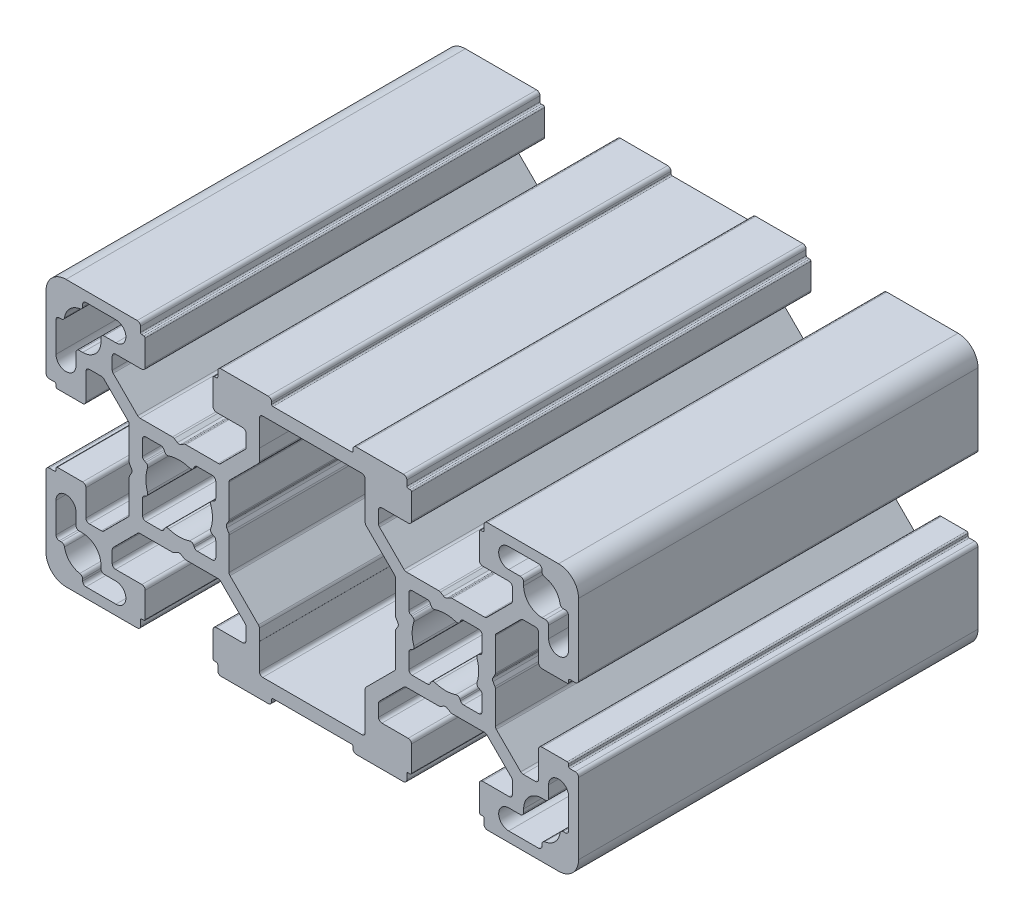
from build123d import *

# Parameters (mm, degrees)
EXTRUDE_1_DEPTH = 60


with BuildPart() as part:
    # Эскиз1 → Бобышка-Вытянуть1 (new body)
    with BuildSketch(Plane.XY):
        with BuildLine():
            Line((0.75, 7.433012702), (0.25, 7.144337567))
            ThreePointArc((0.25, 7.144337567), (0, 7.077350269), (-0.25, 7.144337567))
            Line((-0.25, 7.144337567), (-0.75, 7.433012702))
            ThreePointArc((-0.75, 7.433012702), (-0.870590477, 7.482962913), (-1, 7.5))
            Line((-1, 7.5), (-5.878679656, 7.5))
            ThreePointArc((-5.878679656, 7.5), (-6.070021373, 7.538060234), (-6.232233047, 7.646446609))
            Line((-6.232233047, 7.646446609), (-9.903553391, 11.317766953))
            ThreePointArc((-9.903553391, 11.317766953), (-10.011939766, 11.479978627), (-10.05, 11.671320344))
            Line((-10.05, 11.671320344), (-10.05, 13.5))
            ThreePointArc((-10.05, 13.5), (-9.903553391, 13.853553391), (-9.55, 14))
            Line((-9.55, 14), (-5.6, 14))
            ThreePointArc((-5.6, 14), (-5.246446609, 14.146446609), (-5.1, 14.5))
            Line((-5.1, 14.5), (-5.1, 18.3))
            ThreePointArc((-5.1, 18.3), (-5.158578644, 18.441421356), (-5.3, 18.5))
            Line((-5.3, 18.5), (-5.6, 18.5))
            ThreePointArc((-5.6, 18.5), (-5.741421356, 18.558578644), (-5.8, 18.7))
            Line((-5.8, 18.7), (-5.8, 19.5))
            ThreePointArc((-5.8, 19.5), (-5.946446609, 19.853553391), (-6.3, 20))
            Line((-6.3, 20), (-17, 20))
            ThreePointArc((-17, 20), (-19.121320344, 19.121320344), (-20, 17))
            Line((-20, 17), (-20, 6.3))
            ThreePointArc((-20, 6.3), (-19.853553391, 5.946446609), (-19.5, 5.8))
            Line((-19.5, 5.8), (-18.7, 5.8))
            ThreePointArc((-18.7, 5.8), (-18.558578644, 5.741421356), (-18.5, 5.6))
            Line((-18.5, 5.6), (-18.5, 5.3))
            ThreePointArc((-18.5, 5.3), (-18.441421356, 5.158578644), (-18.3, 5.1))
            Line((-18.3, 5.1), (-14.5, 5.1))
            ThreePointArc((-14.5, 5.1), (-14.146446609, 5.246446609), (-14, 5.6))
            Line((-14, 5.6), (-14, 9.55))
            ThreePointArc((-14, 9.55), (-13.853553391, 9.903553391), (-13.5, 10.05))
            Line((-13.5, 10.05), (-11.671320344, 10.05))
            ThreePointArc((-11.671320344, 10.05), (-11.479978627, 10.011939766), (-11.317766953, 9.903553391))
            Line((-11.317766953, 9.903553391), (-7.646446609, 6.232233047))
            ThreePointArc((-7.646446609, 6.232233047), (-7.538060234, 6.070021373), (-7.5, 5.878679656))
            Line((-7.5, 5.878679656), (-7.5, 1))
            ThreePointArc((-7.5, 1), (-7.482962913, 0.870590477), (-7.433012702, 0.75))
            Line((-7.433012702, 0.75), (-7.144337567, 0.25))
            ThreePointArc((-7.144337567, 0.25), (-7.077350269, 0), (-7.144337567, -0.25))
            Line((-7.144337567, -0.25), (-7.433012702, -0.75))
            ThreePointArc((-7.433012702, -0.75), (-7.482962913, -0.870590477), (-7.5, -1))
            Line((-7.5, -1), (-7.5, -5.878679656))
            ThreePointArc((-7.5, -5.878679656), (-7.538060234, -6.070021373), (-7.646446609, -6.232233047))
            Line((-7.646446609, -6.232233047), (-11.317766953, -9.903553391))
            ThreePointArc((-11.317766953, -9.903553391), (-11.479978627, -10.011939766), (-11.671320344, -10.05))
            Line((-11.671320344, -10.05), (-13.5, -10.05))
            ThreePointArc((-13.5, -10.05), (-13.853553391, -9.903553391), (-14, -9.55))
            Line((-14, -9.55), (-14, -5.6))
            ThreePointArc((-14, -5.6), (-14.146446609, -5.246446609), (-14.5, -5.1))
            Line((-14.5, -5.1), (-18.3, -5.1))
            ThreePointArc((-18.3, -5.1), (-18.441421356, -5.158578644), (-18.5, -5.3))
            Line((-18.5, -5.3), (-18.5, -5.6))
            ThreePointArc((-18.5, -5.6), (-18.558578644, -5.741421356), (-18.7, -5.8))
            Line((-18.7, -5.8), (-19.5, -5.8))
            ThreePointArc((-19.5, -5.8), (-19.853553391, -5.946446609), (-20, -6.3))
            Line((-20, -6.3), (-20, -17))
            ThreePointArc((-20, -17), (-19.121320344, -19.121320344), (-17, -20))
            Line((-17, -20), (-6.3, -20))
            ThreePointArc((-6.3, -20), (-5.946446609, -19.853553391), (-5.8, -19.5))
            Line((-5.8, -19.5), (-5.8, -18.7))
            ThreePointArc((-5.8, -18.7), (-5.741421356, -18.558578644), (-5.6, -18.5))
            Line((-5.6, -18.5), (-5.3, -18.5))
            ThreePointArc((-5.3, -18.5), (-5.158578644, -18.441421356), (-5.1, -18.3))
            Line((-5.1, -18.3), (-5.1, -14.5))
            ThreePointArc((-5.1, -14.5), (-5.246446609, -14.146446609), (-5.6, -14))
            Line((-5.6, -14), (-9.55, -14))
            ThreePointArc((-9.55, -14), (-9.903553391, -13.853553391), (-10.05, -13.5))
            Line((-10.05, -13.5), (-10.05, -11.671320344))
            ThreePointArc((-10.05, -11.671320344), (-10.011939766, -11.479978627), (-9.903553391, -11.317766953))
            Line((-9.903553391, -11.317766953), (-6.232233047, -7.646446609))
            ThreePointArc((-6.232233047, -7.646446609), (-6.070021373, -7.538060234), (-5.878679656, -7.5))
            Line((-5.878679656, -7.5), (-1, -7.5))
            ThreePointArc((-1, -7.5), (-0.870590477, -7.482962913), (-0.75, -7.433012702))
            Line((-0.75, -7.433012702), (-0.25, -7.144337567))
            ThreePointArc((-0.25, -7.144337567), (0, -7.077350269), (0.25, -7.144337567))
            Line((0.25, -7.144337567), (0.75, -7.433012702))
            ThreePointArc((0.75, -7.433012702), (0.870590477, -7.482962913), (1, -7.5))
            Line((1, -7.5), (5.878679656, -7.5))
            ThreePointArc((5.878679656, -7.5), (6.070021373, -7.538060234), (6.232233047, -7.646446609))
            Line((6.232233047, -7.646446609), (9.903553391, -11.317766953))
            ThreePointArc((9.903553391, -11.317766953), (10.011939766, -11.479978627), (10.05, -11.671320344))
            Line((10.05, -11.671320344), (10.05, -13.5))
            ThreePointArc((10.05, -13.5), (9.903553391, -13.853553391), (9.55, -14))
            Line((9.55, -14), (5.6, -14))
            ThreePointArc((5.6, -14), (5.246446609, -14.146446609), (5.1, -14.5))
            Line((5.1, -14.5), (5.1, -18.3))
            ThreePointArc((5.1, -18.3), (5.158578644, -18.441421356), (5.3, -18.5))
            Line((5.3, -18.5), (5.6, -18.5))
            ThreePointArc((5.6, -18.5), (5.741421356, -18.558578644), (5.8, -18.7))
            Line((5.8, -18.7), (5.8, -19.5))
            ThreePointArc((5.8, -19.5), (5.946446609, -19.853553391), (6.3, -20))
            Line((6.3, -20), (13.39, -20))
            ThreePointArc((13.39, -20), (13.743553391, -19.853553391), (13.89, -19.5))
            Line((13.89, -19.5), (13.89, -19.2))
            ThreePointArc((13.89, -19.2), (13.948578644, -19.058578644), (14.09, -19))
            Line((14.09, -19), (25.91, -19))
            ThreePointArc((25.91, -19), (26.051421356, -19.058578644), (26.11, -19.2))
            Line((26.11, -19.2), (26.11, -19.5))
            ThreePointArc((26.11, -19.5), (26.256446609, -19.853553391), (26.61, -20))
            Line((26.61, -20), (33.7, -20))
            ThreePointArc((33.7, -20), (34.053553391, -19.853553391), (34.2, -19.5))
            Line((34.2, -19.5), (34.2, -18.7))
            ThreePointArc((34.2, -18.7), (34.258578644, -18.558578644), (34.4, -18.5))
            Line((34.4, -18.5), (34.7, -18.5))
            ThreePointArc((34.7, -18.5), (34.841421356, -18.441421356), (34.9, -18.3))
            Line((34.9, -18.3), (34.9, -14.5))
            ThreePointArc((34.9, -14.5), (34.753553391, -14.146446609), (34.4, -14))
            Line((34.4, -14), (30.45, -14))
            ThreePointArc((30.45, -14), (30.096446609, -13.853553391), (29.95, -13.5))
            Line((29.95, -13.5), (29.95, -11.671320344))
            ThreePointArc((29.95, -11.671320344), (29.988060234, -11.479978627), (30.096446609, -11.317766953))
            Line((30.096446609, -11.317766953), (33.767766953, -7.646446609))
            ThreePointArc((33.767766953, -7.646446609), (33.929978627, -7.538060234), (34.121320344, -7.5))
            Line((34.121320344, -7.5), (39, -7.5))
            ThreePointArc((39, -7.5), (39.129409523, -7.482962913), (39.25, -7.433012702))
            Line((39.25, -7.433012702), (39.75, -7.144337567))
            ThreePointArc((39.75, -7.144337567), (40, -7.077350269), (40.25, -7.144337567))
            Line((40.25, -7.144337567), (40.75, -7.433012702))
            ThreePointArc((40.75, -7.433012702), (40.870590477, -7.482962913), (41, -7.5))
            Line((41, -7.5), (45.878679656, -7.5))
            ThreePointArc((45.878679656, -7.5), (46.070021373, -7.538060234), (46.232233047, -7.646446609))
            Line((46.232233047, -7.646446609), (49.903553391, -11.317766953))
            ThreePointArc((49.903553391, -11.317766953), (50.011939766, -11.479978627), (50.05, -11.671320344))
            Line((50.05, -11.671320344), (50.05, -13.5))
            ThreePointArc((50.05, -13.5), (49.903553391, -13.853553391), (49.55, -14))
            Line((49.55, -14), (45.6, -14))
            ThreePointArc((45.6, -14), (45.246446609, -14.146446609), (45.1, -14.5))
            Line((45.1, -14.5), (45.1, -18.3))
            ThreePointArc((45.1, -18.3), (45.158578644, -18.441421356), (45.3, -18.5))
            Line((45.3, -18.5), (45.6, -18.5))
            ThreePointArc((45.6, -18.5), (45.741421356, -18.558578644), (45.8, -18.7))
            Line((45.8, -18.7), (45.8, -19.5))
            ThreePointArc((45.8, -19.5), (45.946446609, -19.853553391), (46.3, -20))
            Line((46.3, -20), (57, -20))
            ThreePointArc((57, -20), (59.121320344, -19.121320344), (60, -17))
            Line((60, -17), (60, -6.3))
            ThreePointArc((60, -6.3), (59.853553391, -5.946446609), (59.5, -5.8))
            Line((59.5, -5.8), (58.7, -5.8))
            ThreePointArc((58.7, -5.8), (58.558578644, -5.741421356), (58.5, -5.6))
            Line((58.5, -5.6), (58.5, -5.3))
            ThreePointArc((58.5, -5.3), (58.441421356, -5.158578644), (58.3, -5.1))
            Line((58.3, -5.1), (54.5, -5.1))
            ThreePointArc((54.5, -5.1), (54.146446609, -5.246446609), (54, -5.6))
            Line((54, -5.6), (54, -9.55))
            ThreePointArc((54, -9.55), (53.853553391, -9.903553391), (53.5, -10.05))
            Line((53.5, -10.05), (51.671320344, -10.05))
            ThreePointArc((51.671320344, -10.05), (51.479978627, -10.011939766), (51.317766953, -9.903553391))
            Line((51.317766953, -9.903553391), (47.646446609, -6.232233047))
            ThreePointArc((47.646446609, -6.232233047), (47.538060234, -6.070021373), (47.5, -5.878679656))
            Line((47.5, -5.878679656), (47.5, -1))
            ThreePointArc((47.5, -1), (47.482962913, -0.870590477), (47.433012702, -0.75))
            Line((47.433012702, -0.75), (47.144337567, -0.25))
            ThreePointArc((47.144337567, -0.25), (47.077350269, 0), (47.144337567, 0.25))
            Line((47.144337567, 0.25), (47.433012702, 0.75))
            ThreePointArc((47.433012702, 0.75), (47.482962913, 0.870590477), (47.5, 1))
            Line((47.5, 1), (47.5, 5.878679656))
            ThreePointArc((47.5, 5.878679656), (47.538060234, 6.070021373), (47.646446609, 6.232233047))
            Line((47.646446609, 6.232233047), (51.317766953, 9.903553391))
            ThreePointArc((51.317766953, 9.903553391), (51.479978627, 10.011939766), (51.671320344, 10.05))
            Line((51.671320344, 10.05), (53.5, 10.05))
            ThreePointArc((53.5, 10.05), (53.853553391, 9.903553391), (54, 9.55))
            Line((54, 9.55), (54, 5.6))
            ThreePointArc((54, 5.6), (54.146446609, 5.246446609), (54.5, 5.1))
            Line((54.5, 5.1), (58.3, 5.1))
            ThreePointArc((58.3, 5.1), (58.441421356, 5.158578644), (58.5, 5.3))
            Line((58.5, 5.3), (58.5, 5.6))
            ThreePointArc((58.5, 5.6), (58.558578644, 5.741421356), (58.7, 5.8))
            Line((58.7, 5.8), (59.5, 5.8))
            ThreePointArc((59.5, 5.8), (59.853553391, 5.946446609), (60, 6.3))
            Line((60, 6.3), (60, 17))
            ThreePointArc((60, 17), (59.121320344, 19.121320344), (57, 20))
            Line((57, 20), (46.3, 20))
            ThreePointArc((46.3, 20), (45.946446609, 19.853553391), (45.8, 19.5))
            Line((45.8, 19.5), (45.8, 18.7))
            ThreePointArc((45.8, 18.7), (45.741421356, 18.558578644), (45.6, 18.5))
            Line((45.6, 18.5), (45.3, 18.5))
            ThreePointArc((45.3, 18.5), (45.158578644, 18.441421356), (45.1, 18.3))
            Line((45.1, 18.3), (45.1, 14.5))
            ThreePointArc((45.1, 14.5), (45.246446609, 14.146446609), (45.6, 14))
            Line((45.6, 14), (49.55, 14))
            ThreePointArc((49.55, 14), (49.903553391, 13.853553391), (50.05, 13.5))
            Line((50.05, 13.5), (50.05, 11.671320344))
            ThreePointArc((50.05, 11.671320344), (50.011939766, 11.479978627), (49.903553391, 11.317766953))
            Line((49.903553391, 11.317766953), (46.232233047, 7.646446609))
            ThreePointArc((46.232233047, 7.646446609), (46.070021373, 7.538060234), (45.878679656, 7.5))
            Line((45.878679656, 7.5), (41, 7.5))
            ThreePointArc((41, 7.5), (40.870590477, 7.482962913), (40.75, 7.433012702))
            Line((40.75, 7.433012702), (40.25, 7.144337567))
            ThreePointArc((40.25, 7.144337567), (40, 7.077350269), (39.75, 7.144337567))
            Line((39.75, 7.144337567), (39.25, 7.433012702))
            ThreePointArc((39.25, 7.433012702), (39.129409523, 7.482962913), (39, 7.5))
            Line((39, 7.5), (34.121320344, 7.5))
            ThreePointArc((34.121320344, 7.5), (33.929978627, 7.538060234), (33.767766953, 7.646446609))
            Line((33.767766953, 7.646446609), (30.096446609, 11.317766953))
            ThreePointArc((30.096446609, 11.317766953), (29.988060234, 11.479978627), (29.95, 11.671320344))
            Line((29.95, 11.671320344), (29.95, 13.5))
            ThreePointArc((29.95, 13.5), (30.096446609, 13.853553391), (30.45, 14))
            Line((30.45, 14), (34.4, 14))
            ThreePointArc((34.4, 14), (34.753553391, 14.146446609), (34.9, 14.5))
            Line((34.9, 14.5), (34.9, 18.3))
            ThreePointArc((34.9, 18.3), (34.841421356, 18.441421356), (34.7, 18.5))
            Line((34.7, 18.5), (34.4, 18.5))
            ThreePointArc((34.4, 18.5), (34.258578644, 18.558578644), (34.2, 18.7))
            Line((34.2, 18.7), (34.2, 19.5))
            ThreePointArc((34.2, 19.5), (34.053553391, 19.853553391), (33.7, 20))
            Line((33.7, 20), (26.61, 20))
            ThreePointArc((26.61, 20), (26.256446609, 19.853553391), (26.11, 19.5))
            Line((26.11, 19.5), (26.11, 19.2))
            ThreePointArc((26.11, 19.2), (26.051421356, 19.058578644), (25.91, 19))
            Line((25.91, 19), (14.09, 19))
            ThreePointArc((14.09, 19), (13.948578644, 19.058578644), (13.89, 19.2))
            Line((13.89, 19.2), (13.89, 19.5))
            ThreePointArc((13.89, 19.5), (13.743553391, 19.853553391), (13.39, 20))
            Line((13.39, 20), (6.3, 20))
            ThreePointArc((6.3, 20), (5.946446609, 19.853553391), (5.8, 19.5))
            Line((5.8, 19.5), (5.8, 18.7))
            ThreePointArc((5.8, 18.7), (5.741421356, 18.558578644), (5.6, 18.5))
            Line((5.6, 18.5), (5.3, 18.5))
            ThreePointArc((5.3, 18.5), (5.158578644, 18.441421356), (5.1, 18.3))
            Line((5.1, 18.3), (5.1, 14.5))
            ThreePointArc((5.1, 14.5), (5.246446609, 14.146446609), (5.6, 14))
            Line((5.6, 14), (9.55, 14))
            ThreePointArc((9.55, 14), (9.903553391, 13.853553391), (10.05, 13.5))
            Line((10.05, 13.5), (10.05, 11.671320344))
            ThreePointArc((10.05, 11.671320344), (10.011939766, 11.479978627), (9.903553391, 11.317766953))
            Line((9.903553391, 11.317766953), (6.232233047, 7.646446609))
            ThreePointArc((6.232233047, 7.646446609), (6.070021373, 7.538060234), (5.878679656, 7.5))
            Line((5.878679656, 7.5), (1, 7.5))
            ThreePointArc((1, 7.5), (0.870590477, 7.482962913), (0.75, 7.433012702))
        make_face()
        with BuildLine():
            ThreePointArc((-18, -14.5), (-18.353553391, -14.353553391), (-18.5, -14))
            Line((-18.5, -14), (-18.5, -9.5))
            ThreePointArc((-18.5, -9.5), (-17, -8), (-15.5, -9.5))
            Line((-15.5, -9.5), (-15.5, -11.25))
            ThreePointArc((-15.5, -11.25), (-15.353553391, -11.603553391), (-15, -11.75))
            Line((-15, -11.75), (-14.5, -11.75))
            ThreePointArc((-14.5, -11.75), (-12.555456352, -12.555456352), (-11.75, -14.5))
            Line((-11.75, -14.5), (-11.75, -15))
            ThreePointArc((-11.75, -15), (-11.603553391, -15.353553391), (-11.25, -15.5))
            Line((-11.25, -15.5), (-9.5, -15.5))
            ThreePointArc((-9.5, -15.5), (-8, -17), (-9.5, -18.5))
            Line((-9.5, -18.5), (-14, -18.5))
            ThreePointArc((-14, -18.5), (-14.353553391, -18.353553391), (-14.5, -18))
            Line((-14.5, -18), (-14.5, -17.711308145))
            ThreePointArc((-14.5, -17.711308145), (-14.620222737, -17.386086327), (-14.923076923, -17.217260738))
            ThreePointArc((-14.923076923, -17.217260738), (-16.444543648, -16.444543648), (-17.217260738, -14.923076923))
            ThreePointArc((-17.217260738, -14.923076923), (-17.386086327, -14.620222737), (-17.711308145, -14.5))
            Line((-17.711308145, -14.5), (-18, -14.5))
        make_face(mode=Mode.SUBTRACT)
        with BuildLine():
            Line((11.317766953, -9.903553391), (7.646446609, -6.232233047))
            ThreePointArc((7.646446609, -6.232233047), (7.538060234, -6.070021373), (7.5, -5.878679656))
            Line((7.5, -5.878679656), (7.5, -1))
            ThreePointArc((7.5, -1), (7.482962913, -0.870590477), (7.433012702, -0.75))
            Line((7.433012702, -0.75), (7.144337567, -0.25))
            ThreePointArc((7.144337567, -0.25), (7.077350269, 0), (7.144337567, 0.25))
            Line((7.144337567, 0.25), (7.433012702, 0.75))
            ThreePointArc((7.433012702, 0.75), (7.482962913, 0.870590477), (7.5, 1))
            Line((7.5, 1), (7.5, 5.878679656))
            ThreePointArc((7.5, 5.878679656), (7.538060234, 6.070021373), (7.646446609, 6.232233047))
            Line((7.646446609, 6.232233047), (11.317766953, 9.903553391))
            Line((11.317766953, 9.903553391), (11.903553391, 10.489339828))
            ThreePointArc((11.903553391, 10.489339828), (12.011939766, 10.651551503), (12.05, 10.842893219))
            Line((12.05, 10.842893219), (12.05, 12.585660172))
            Line((12.05, 12.585660172), (12.06499038, 12.580129564))
            Line((12.06499038, 12.580129564), (12.051701545, 16.498304216))
            ThreePointArc((12.051701545, 16.498304216), (12.197546236, 16.852953331), (12.55169867, 17))
            Line((12.55169867, 17), (27.44830133, 17))
            ThreePointArc((27.44830133, 17), (27.802453764, 16.852953331), (27.948298455, 16.498304216))
            Line((27.948298455, 16.498304216), (27.93500962, 12.580129564))
            Line((27.93500962, 12.580129564), (27.95, 12.585660172))
            Line((27.95, 12.585660172), (27.95, 10.842893219))
            ThreePointArc((27.95, 10.842893219), (27.988060234, 10.651551503), (28.096446609, 10.489339828))
            Line((28.096446609, 10.489339828), (28.682233047, 9.903553391))
            Line((28.682233047, 9.903553391), (32.353553391, 6.232233047))
            ThreePointArc((32.353553391, 6.232233047), (32.461939766, 6.070021373), (32.5, 5.878679656))
            Line((32.5, 5.878679656), (32.5, 1))
            ThreePointArc((32.5, 1), (32.517037087, 0.870590477), (32.566987298, 0.75))
            Line((32.566987298, 0.75), (32.855662433, 0.25))
            ThreePointArc((32.855662433, 0.25), (32.922649731, 0), (32.855662433, -0.25))
            Line((32.855662433, -0.25), (32.566987298, -0.75))
            ThreePointArc((32.566987298, -0.75), (32.517037087, -0.870590477), (32.5, -1))
            Line((32.5, -1), (32.5, -5.878679656))
            ThreePointArc((32.5, -5.878679656), (32.461939766, -6.070021373), (32.353553391, -6.232233047))
            Line((32.353553391, -6.232233047), (28.682233047, -9.903553391))
            Line((28.682233047, -9.903553391), (28.096446609, -10.489339828))
            ThreePointArc((28.096446609, -10.489339828), (27.988060234, -10.651551503), (27.95, -10.842893219))
            Line((27.95, -10.842893219), (27.95, -12.585660172))
            Line((27.95, -12.585660172), (27.93500962, -12.580129564))
            Line((27.93500962, -12.580129564), (27.948298455, -16.498304216))
            ThreePointArc((27.948298455, -16.498304216), (27.802453764, -16.852953331), (27.44830133, -17))
            Line((27.44830133, -17), (12.55169867, -17))
            ThreePointArc((12.55169867, -17), (12.197546236, -16.852953331), (12.051701545, -16.498304216))
            Line((12.051701545, -16.498304216), (12.06499038, -12.580129564))
            Line((12.06499038, -12.580129564), (12.05, -12.585660172))
            Line((12.05, -12.585660172), (12.05, -10.842893219))
            ThreePointArc((12.05, -10.842893219), (12.011939766, -10.651551503), (11.903553391, -10.489339828))
            Line((11.903553391, -10.489339828), (11.317766953, -9.903553391))
        make_face(mode=Mode.SUBTRACT)
        with BuildLine():
            Line((54.5, -17.711308145), (54.5, -18))
            ThreePointArc((54.5, -18), (54.353553391, -18.353553391), (54, -18.5))
            Line((54, -18.5), (49.5, -18.5))
            ThreePointArc((49.5, -18.5), (48, -17), (49.5, -15.5))
            Line((49.5, -15.5), (51.25, -15.5))
            ThreePointArc((51.25, -15.5), (51.603553391, -15.353553391), (51.75, -15))
            Line((51.75, -15), (51.75, -14.5))
            ThreePointArc((51.75, -14.5), (52.555456352, -12.555456352), (54.5, -11.75))
            Line((54.5, -11.75), (55, -11.75))
            ThreePointArc((55, -11.75), (55.353553391, -11.603553391), (55.5, -11.25))
            Line((55.5, -11.25), (55.5, -9.5))
            ThreePointArc((55.5, -9.5), (57, -8), (58.5, -9.5))
            Line((58.5, -9.5), (58.5, -14))
            ThreePointArc((58.5, -14), (58.353553391, -14.353553391), (58, -14.5))
            Line((58, -14.5), (57.711308145, -14.5))
            ThreePointArc((57.711308145, -14.5), (57.386086327, -14.620222737), (57.217260738, -14.923076923))
            ThreePointArc((57.217260738, -14.923076923), (56.444543648, -16.444543648), (54.923076923, -17.217260738))
            ThreePointArc((54.923076923, -17.217260738), (54.620222737, -17.386086327), (54.5, -17.711308145))
        make_face(mode=Mode.SUBTRACT)
        with BuildLine():
            Line((-5.020474811, 2.191496514), (-5.199374534, 2.269284327))
            ThreePointArc((-5.199374534, 2.269284327), (-5.418143078, 2.45366775), (-5.5, 2.727814365))
            Line((-5.5, 2.727814365), (-5.5, 5))
            ThreePointArc((-5.5, 5), (-5.353553391, 5.353553391), (-5, 5.5))
            Line((-5, 5.5), (-2.727814365, 5.5))
            ThreePointArc((-2.727814365, 5.5), (-2.45366775, 5.418143078), (-2.269284327, 5.199374534))
            Line((-2.269284327, 5.199374534), (-2.191496514, 5.020474811))
            ThreePointArc((-2.191496514, 5.020474811), (-1.936869058, 4.763314859), (-1.57542407, 4.745317587))
            ThreePointArc((-1.57542407, 4.745317587), (0, 5), (1.57542407, 4.745317587))
            ThreePointArc((1.57542407, 4.745317587), (1.936869058, 4.763314859), (2.191496514, 5.020474811))
            Line((2.191496514, 5.020474811), (2.269284327, 5.199374534))
            ThreePointArc((2.269284327, 5.199374534), (2.45366775, 5.418143078), (2.727814365, 5.5))
            Line((2.727814365, 5.5), (5, 5.5))
            ThreePointArc((5, 5.5), (5.353553391, 5.353553391), (5.5, 5))
            Line((5.5, 5), (5.5, 2.727814365))
            ThreePointArc((5.5, 2.727814365), (5.418143078, 2.45366775), (5.199374534, 2.269284327))
            Line((5.199374534, 2.269284327), (5.020474811, 2.191496514))
            ThreePointArc((5.020474811, 2.191496514), (4.763314859, 1.936869058), (4.745317587, 1.57542407))
            ThreePointArc((4.745317587, 1.57542407), (5, 0), (4.745317587, -1.57542407))
            ThreePointArc((4.745317587, -1.57542407), (4.763314859, -1.936869058), (5.020474811, -2.191496514))
            Line((5.020474811, -2.191496514), (5.199374534, -2.269284327))
            ThreePointArc((5.199374534, -2.269284327), (5.418143078, -2.45366775), (5.5, -2.727814365))
            Line((5.5, -2.727814365), (5.5, -5))
            ThreePointArc((5.5, -5), (5.353553391, -5.353553391), (5, -5.5))
            Line((5, -5.5), (2.727814365, -5.5))
            ThreePointArc((2.727814365, -5.5), (2.45366775, -5.418143078), (2.269284327, -5.199374534))
            Line((2.269284327, -5.199374534), (2.191496514, -5.020474811))
            ThreePointArc((2.191496514, -5.020474811), (1.936869058, -4.763314859), (1.57542407, -4.745317587))
            ThreePointArc((1.57542407, -4.745317587), (0, -5), (-1.57542407, -4.745317587))
            ThreePointArc((-1.57542407, -4.745317587), (-1.936869058, -4.763314859), (-2.191496514, -5.020474811))
            Line((-2.191496514, -5.020474811), (-2.269284327, -5.199374534))
            ThreePointArc((-2.269284327, -5.199374534), (-2.45366775, -5.418143078), (-2.727814365, -5.5))
            Line((-2.727814365, -5.5), (-5, -5.5))
            ThreePointArc((-5, -5.5), (-5.353553391, -5.353553391), (-5.5, -5))
            Line((-5.5, -5), (-5.5, -2.727814365))
            ThreePointArc((-5.5, -2.727814365), (-5.418143078, -2.45366775), (-5.199374534, -2.269284327))
            Line((-5.199374534, -2.269284327), (-5.020474811, -2.191496514))
            ThreePointArc((-5.020474811, -2.191496514), (-4.763314859, -1.936869058), (-4.745317587, -1.57542407))
            ThreePointArc((-4.745317587, -1.57542407), (-5, 0), (-4.745317587, 1.57542407))
            ThreePointArc((-4.745317587, 1.57542407), (-4.763314859, 1.936869058), (-5.020474811, 2.191496514))
        make_face(mode=Mode.SUBTRACT)
        with BuildLine():
            Line((-14.5, 17.711308145), (-14.5, 18))
            ThreePointArc((-14.5, 18), (-14.353553391, 18.353553391), (-14, 18.5))
            Line((-14, 18.5), (-9.5, 18.5))
            ThreePointArc((-9.5, 18.5), (-8, 17), (-9.5, 15.5))
            Line((-9.5, 15.5), (-11.25, 15.5))
            ThreePointArc((-11.25, 15.5), (-11.603553391, 15.353553391), (-11.75, 15))
            Line((-11.75, 15), (-11.75, 14.5))
            ThreePointArc((-11.75, 14.5), (-12.555456352, 12.555456352), (-14.5, 11.75))
            Line((-14.5, 11.75), (-15, 11.75))
            ThreePointArc((-15, 11.75), (-15.353553391, 11.603553391), (-15.5, 11.25))
            Line((-15.5, 11.25), (-15.5, 9.5))
            ThreePointArc((-15.5, 9.5), (-17, 8), (-18.5, 9.5))
            Line((-18.5, 9.5), (-18.5, 14))
            ThreePointArc((-18.5, 14), (-18.353553391, 14.353553391), (-18, 14.5))
            Line((-18, 14.5), (-17.711308145, 14.5))
            ThreePointArc((-17.711308145, 14.5), (-17.386086327, 14.620222737), (-17.217260738, 14.923076923))
            ThreePointArc((-17.217260738, 14.923076923), (-16.444543648, 16.444543648), (-14.923076923, 17.217260738))
            ThreePointArc((-14.923076923, 17.217260738), (-14.620222737, 17.386086327), (-14.5, 17.711308145))
        make_face(mode=Mode.SUBTRACT)
        with BuildLine():
            Line((45.020474811, -2.191496514), (45.199374534, -2.269284327))
            ThreePointArc((45.199374534, -2.269284327), (45.418143078, -2.45366775), (45.5, -2.727814365))
            Line((45.5, -2.727814365), (45.5, -5))
            ThreePointArc((45.5, -5), (45.353553391, -5.353553391), (45, -5.5))
            Line((45, -5.5), (42.727814365, -5.5))
            ThreePointArc((42.727814365, -5.5), (42.45366775, -5.418143078), (42.269284327, -5.199374534))
            Line((42.269284327, -5.199374534), (42.191496514, -5.020474811))
            ThreePointArc((42.191496514, -5.020474811), (41.936869058, -4.763314859), (41.57542407, -4.745317587))
            ThreePointArc((41.57542407, -4.745317587), (40, -5), (38.42457593, -4.745317587))
            ThreePointArc((38.42457593, -4.745317587), (38.063130942, -4.763314859), (37.808503486, -5.020474811))
            Line((37.808503486, -5.020474811), (37.730715673, -5.199374534))
            ThreePointArc((37.730715673, -5.199374534), (37.54633225, -5.418143078), (37.272185635, -5.5))
            Line((37.272185635, -5.5), (35, -5.5))
            ThreePointArc((35, -5.5), (34.646446609, -5.353553391), (34.5, -5))
            Line((34.5, -5), (34.5, -2.727814365))
            ThreePointArc((34.5, -2.727814365), (34.581856922, -2.45366775), (34.800625466, -2.269284327))
            Line((34.800625466, -2.269284327), (34.979525189, -2.191496514))
            ThreePointArc((34.979525189, -2.191496514), (35.236685141, -1.936869058), (35.254682413, -1.57542407))
            ThreePointArc((35.254682413, -1.57542407), (35, 0), (35.254682413, 1.57542407))
            ThreePointArc((35.254682413, 1.57542407), (35.236685141, 1.936869058), (34.979525189, 2.191496514))
            Line((34.979525189, 2.191496514), (34.800625466, 2.269284327))
            ThreePointArc((34.800625466, 2.269284327), (34.581856922, 2.45366775), (34.5, 2.727814365))
            Line((34.5, 2.727814365), (34.5, 5))
            ThreePointArc((34.5, 5), (34.646446609, 5.353553391), (35, 5.5))
            Line((35, 5.5), (37.272185635, 5.5))
            ThreePointArc((37.272185635, 5.5), (37.54633225, 5.418143078), (37.730715673, 5.199374534))
            Line((37.730715673, 5.199374534), (37.808503486, 5.020474811))
            ThreePointArc((37.808503486, 5.020474811), (38.063130942, 4.763314859), (38.42457593, 4.745317587))
            ThreePointArc((38.42457593, 4.745317587), (40, 5), (41.57542407, 4.745317587))
            ThreePointArc((41.57542407, 4.745317587), (41.936869058, 4.763314859), (42.191496514, 5.020474811))
            Line((42.191496514, 5.020474811), (42.269284327, 5.199374534))
            ThreePointArc((42.269284327, 5.199374534), (42.45366775, 5.418143078), (42.727814365, 5.5))
            Line((42.727814365, 5.5), (45, 5.5))
            ThreePointArc((45, 5.5), (45.353553391, 5.353553391), (45.5, 5))
            Line((45.5, 5), (45.5, 2.727814365))
            ThreePointArc((45.5, 2.727814365), (45.418143078, 2.45366775), (45.199374534, 2.269284327))
            Line((45.199374534, 2.269284327), (45.020474811, 2.191496514))
            ThreePointArc((45.020474811, 2.191496514), (44.763314859, 1.936869058), (44.745317587, 1.57542407))
            ThreePointArc((44.745317587, 1.57542407), (45, 0), (44.745317587, -1.57542407))
            ThreePointArc((44.745317587, -1.57542407), (44.763314859, -1.936869058), (45.020474811, -2.191496514))
        make_face(mode=Mode.SUBTRACT)
        with BuildLine():
            ThreePointArc((58, 14.5), (58.353553391, 14.353553391), (58.5, 14))
            Line((58.5, 14), (58.5, 9.5))
            ThreePointArc((58.5, 9.5), (57, 8), (55.5, 9.5))
            Line((55.5, 9.5), (55.5, 11.25))
            ThreePointArc((55.5, 11.25), (55.353553391, 11.603553391), (55, 11.75))
            Line((55, 11.75), (54.5, 11.75))
            ThreePointArc((54.5, 11.75), (52.555456352, 12.555456352), (51.75, 14.5))
            Line((51.75, 14.5), (51.75, 15))
            ThreePointArc((51.75, 15), (51.603553391, 15.353553391), (51.25, 15.5))
            Line((51.25, 15.5), (49.5, 15.5))
            ThreePointArc((49.5, 15.5), (48, 17), (49.5, 18.5))
            Line((49.5, 18.5), (54, 18.5))
            ThreePointArc((54, 18.5), (54.353553391, 18.353553391), (54.5, 18))
            Line((54.5, 18), (54.5, 17.711308145))
            ThreePointArc((54.5, 17.711308145), (54.620222737, 17.386086327), (54.923076923, 17.217260738))
            ThreePointArc((54.923076923, 17.217260738), (56.444543648, 16.444543648), (57.217260738, 14.923076923))
            ThreePointArc((57.217260738, 14.923076923), (57.386086327, 14.620222737), (57.711308145, 14.5))
            Line((57.711308145, 14.5), (58, 14.5))
        make_face(mode=Mode.SUBTRACT)
    extrude(amount=EXTRUDE_1_DEPTH)


solid = part.part
